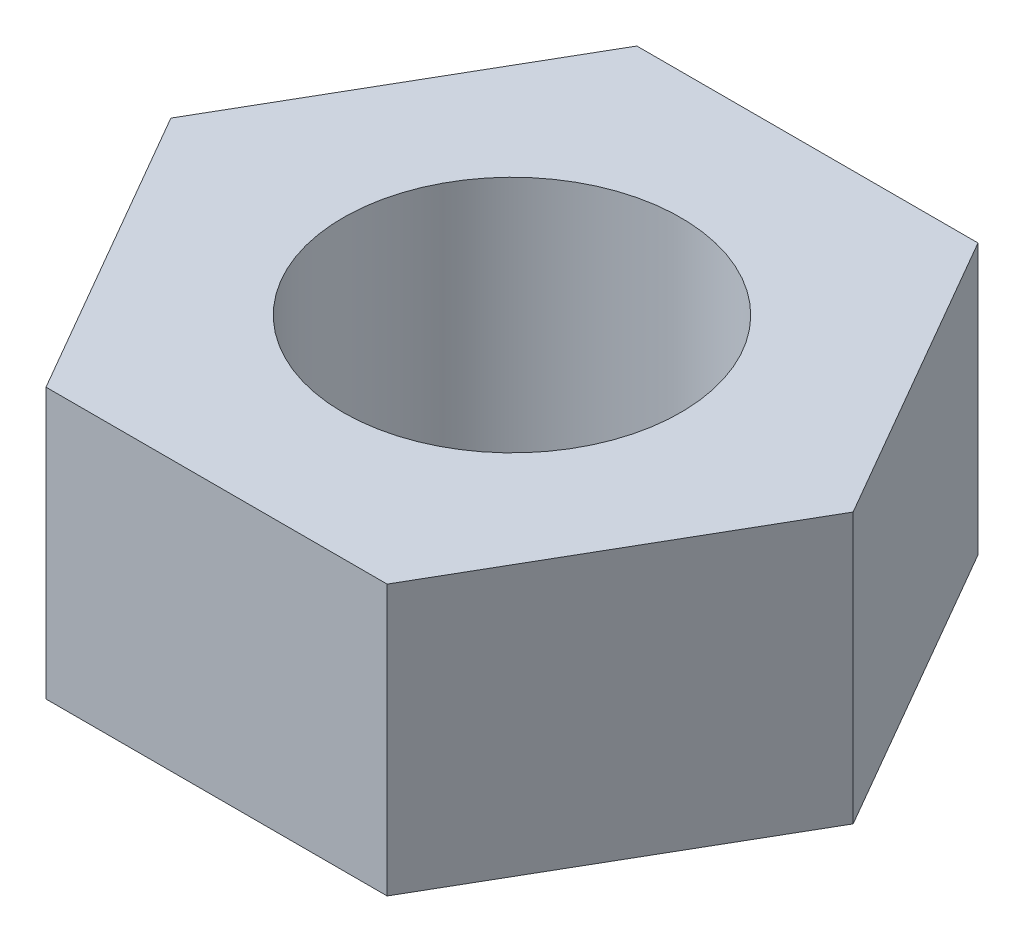
from build123d import *

# Parameters (mm, degrees)
CROQUIS1_R              = 2
SALIENTE_EXTRUIR1_DEPTH = 3.2


with BuildPart() as part:
    # Croquis1 → Saliente-Extruir1 (new body)
    with BuildSketch(Plane(origin=(0, 0, 0), x_dir=(1, 0, 0), z_dir=(0, 1, 0))):
        Polygon((-2.020725942, 3.5), (-4.041451884, 0), (-2.020725942, -3.5), (2.020725942, -3.5), (4.041451884, 0), (2.020725942, 3.5), align=None)
        Circle(CROQUIS1_R, mode=Mode.SUBTRACT)
    extrude(amount=SALIENTE_EXTRUIR1_DEPTH)


solid = part.part
